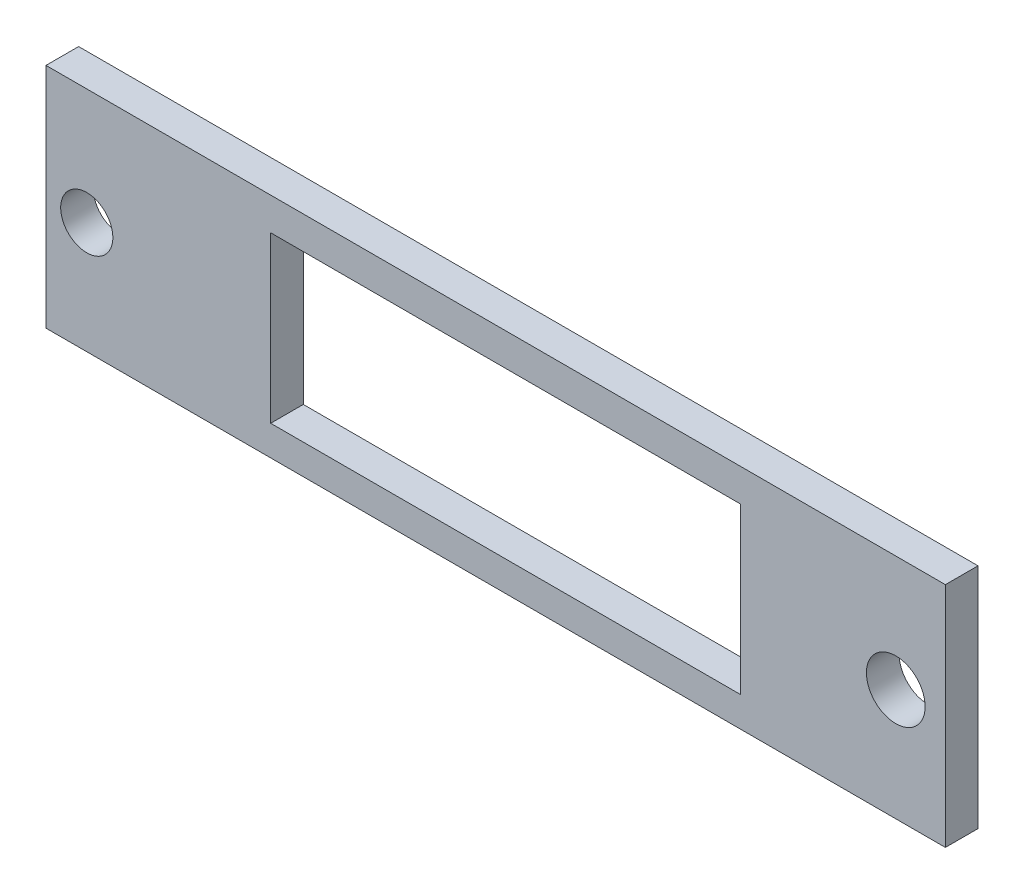
from build123d import *

# Parameters (mm, degrees)
SKETCH1_W           = 55.141682948
SKETCH1_H           = 13.954968186
SKETCH1_R           = 1.8
SKETCH1_R_2         = 1.6
SKETCH1_W_2         = 28.7955252
SKETCH1_H_2         = 10.115782048
BOSS_EXTRUDE1_DEPTH = 2


with BuildPart() as part:
    # Sketch1 → Boss-Extrude1 (new body)
    with BuildSketch(Plane.XY):
        with Locations((0.270841474, -0.077484093)):
            Rectangle(SKETCH1_W, SKETCH1_H)
        with Locations((24.8, -0.2)):
            Circle(SKETCH1_R, mode=Mode.SUBTRACT)
        with Locations((-24.8, -0.2)):
            Circle(SKETCH1_R_2, mode=Mode.SUBTRACT)
        with Locations((0.873078874, -0.157891024)):
            Rectangle(SKETCH1_W_2, SKETCH1_H_2, mode=Mode.SUBTRACT)
    extrude(amount=BOSS_EXTRUDE1_DEPTH)


solid = part.part
